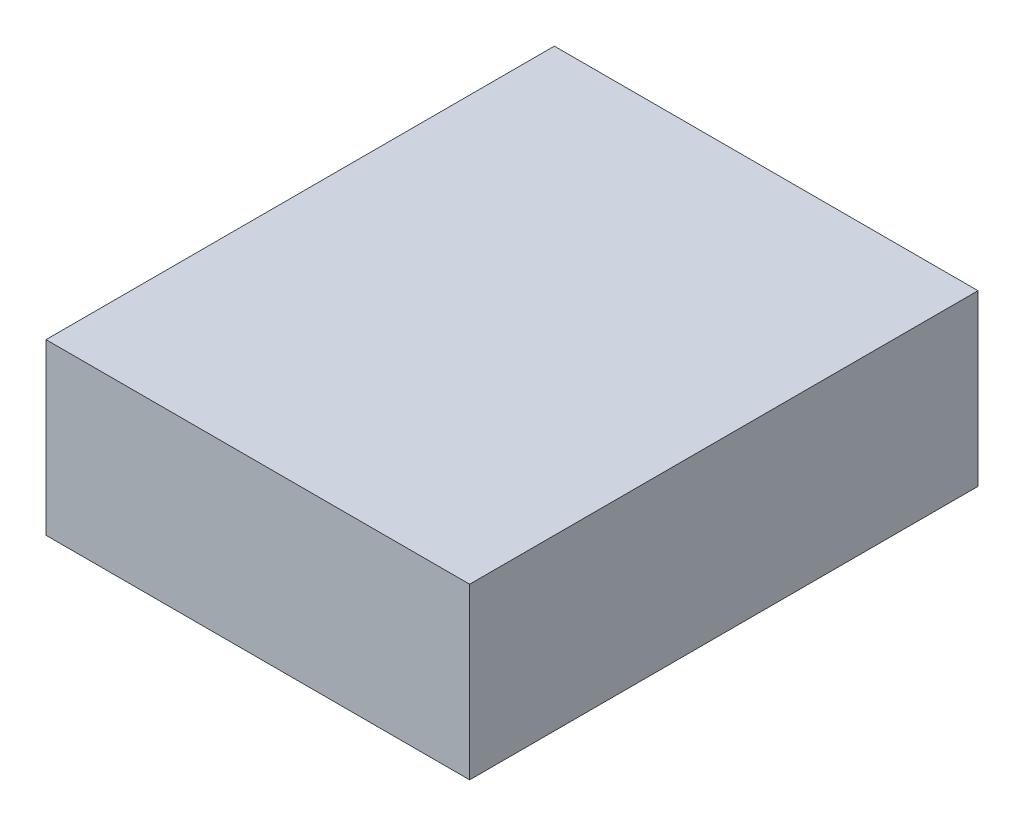
from build123d import *

# Parameters (mm, degrees)
SKETCH1_W           = 5
SKETCH1_H           = 6
BOSS_EXTRUDE1_DEPTH = 2


with BuildPart() as part:
    # Sketch1 → Boss-Extrude1 (new body)
    with BuildSketch(Plane(origin=(0, 0, 0), x_dir=(1, 0, 0), z_dir=(0, 1, 0))):
        Rectangle(SKETCH1_W, SKETCH1_H)
    extrude(amount=BOSS_EXTRUDE1_DEPTH)


solid = part.part
